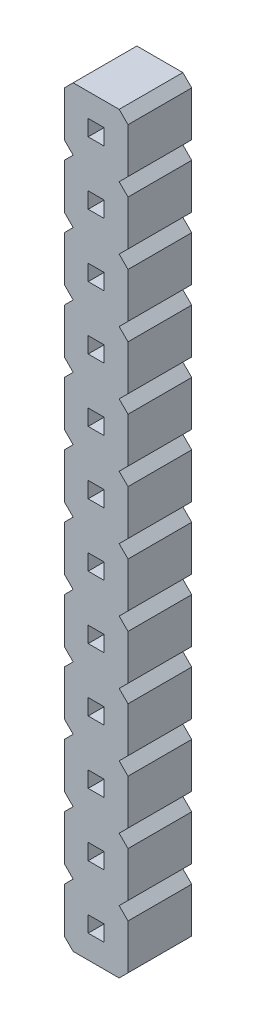
from build123d import *

# Parameters (mm, degrees)
PIN_DRAWING_W       = 0.636
PIN_DRAWING_H       = 0.636
BOSS_EXTRUDE1_DEPTH = 2.54


with BuildPart() as part:
    # pin_drawing → Boss-Extrude1 (new body)
    with BuildSketch(Plane.XY):
        Polygon((0, 2.146446609), (0, 0.353553391), (0.353553391, 0), (0, -0.353553391), (0, -2.146446609), (0.353553391, -2.5), (2.187446609, -2.5), (2.541, -2.146446609), (2.541, -0.353553391), (2.187446609, 0), (2.541, 0.353553391), (2.541, 2.146446609), (2.187446609, 2.5), (2.541, 2.853553391), (2.541, 4.646446609), (2.187446609, 5), (2.541, 5.353553391), (2.541, 7.146446609), (2.187446609, 7.5), (2.541, 7.853553391), (2.541, 9.646446609), (2.187446609, 10), (2.541, 10.353553391), (2.541, 12.146446609), (2.187446609, 12.5), (2.541, 12.853553391), (2.541, 14.646446609), (2.187446609, 15), (2.541, 15.353553391), (2.541, 17.146446609), (2.187446609, 17.5), (2.541, 17.853553391), (2.541, 19.646446609), (2.187446609, 20), (2.541, 20.353553391), (2.541, 22.146446609), (2.187446609, 22.5), (2.541, 22.853553391), (2.541, 24.646446609), (2.187446609, 25), (2.541, 25.353553391), (2.541, 27.146446609), (2.187446609, 27.5), (0.353553391, 27.5), (0, 27.146446609), (0, 25.353553391), (0.353553391, 25), (0, 24.646446609), (0, 22.853553391), (0.353553391, 22.5), (0, 22.146446609), (0, 20.353553391), (0.353553391, 20), (0, 19.646446609), (0, 17.853553391), (0.353553391, 17.5), (0, 17.146446609), (0, 15.353553391), (0.353553391, 15), (0, 14.646446609), (0, 12.853553391), (0.353553391, 12.5), (0, 12.146446609), (0, 10.353553391), (0.353553391, 10), (0, 9.646446609), (0, 7.853553391), (0.353553391, 7.5), (0, 7.146446609), (0, 5.353553391), (0.353553391, 5), (0, 4.646446609), (0, 2.853553391), (0.353553391, 2.5), align=None)
        with Locations((1.2705, -1.25)):
            Rectangle(PIN_DRAWING_W, PIN_DRAWING_H, mode=Mode.SUBTRACT)
        with Locations((1.2705, 1.25)):
            Rectangle(PIN_DRAWING_W, PIN_DRAWING_H, mode=Mode.SUBTRACT)
        with Locations((1.2705, 3.75)):
            Rectangle(PIN_DRAWING_W, PIN_DRAWING_H, mode=Mode.SUBTRACT)
        with Locations((1.2705, 6.25)):
            Rectangle(PIN_DRAWING_W, PIN_DRAWING_H, mode=Mode.SUBTRACT)
        with Locations((1.2705, 8.75)):
            Rectangle(PIN_DRAWING_W, PIN_DRAWING_H, mode=Mode.SUBTRACT)
        with Locations((1.2705, 11.25)):
            Rectangle(PIN_DRAWING_W, PIN_DRAWING_H, mode=Mode.SUBTRACT)
        with Locations((1.2705, 13.75)):
            Rectangle(PIN_DRAWING_W, PIN_DRAWING_H, mode=Mode.SUBTRACT)
        with Locations((1.2705, 16.25)):
            Rectangle(PIN_DRAWING_W, PIN_DRAWING_H, mode=Mode.SUBTRACT)
        with Locations((1.2705, 18.75)):
            Rectangle(PIN_DRAWING_W, PIN_DRAWING_H, mode=Mode.SUBTRACT)
        with Locations((1.2705, 21.25)):
            Rectangle(PIN_DRAWING_W, PIN_DRAWING_H, mode=Mode.SUBTRACT)
        with Locations((1.2705, 23.75)):
            Rectangle(PIN_DRAWING_W, PIN_DRAWING_H, mode=Mode.SUBTRACT)
        with Locations((1.2705, 26.25)):
            Rectangle(PIN_DRAWING_W, PIN_DRAWING_H, mode=Mode.SUBTRACT)
    extrude(amount=BOSS_EXTRUDE1_DEPTH)


solid = part.part
